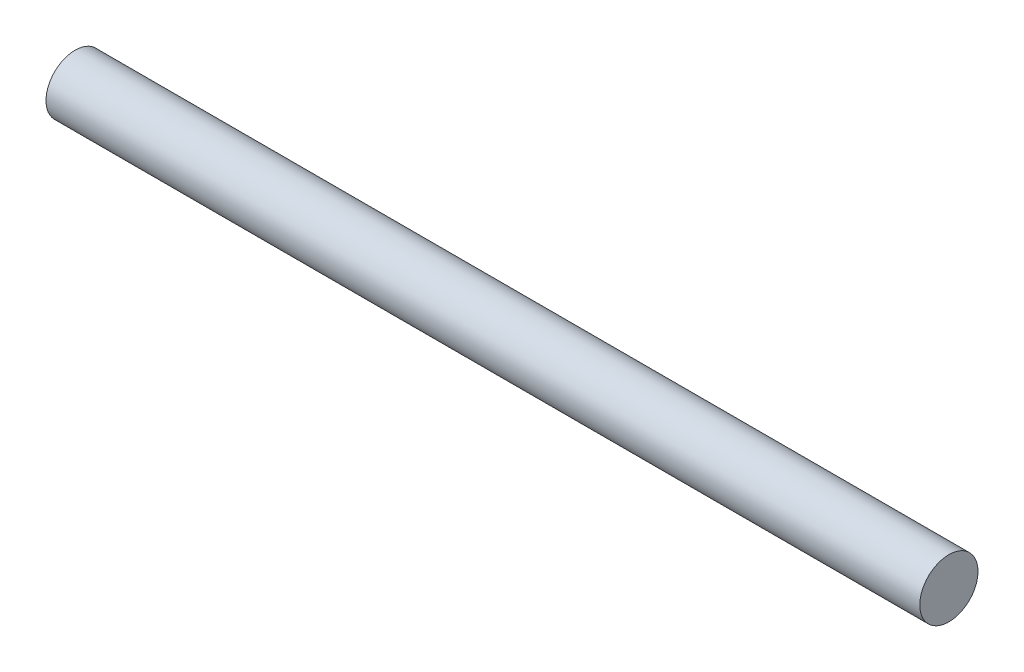
from build123d import *


with BuildPart() as part:
    # Sketch1 → Revolve4 (revolve)
    with BuildSketch(Plane.XY):
        Polygon((75, 0), (0, 0), (-75, 0), (-75, 5), (75, 5), align=None)
    revolve(axis=Axis((0, 0, 0), (-1, 0, 0)))


solid = part.part
